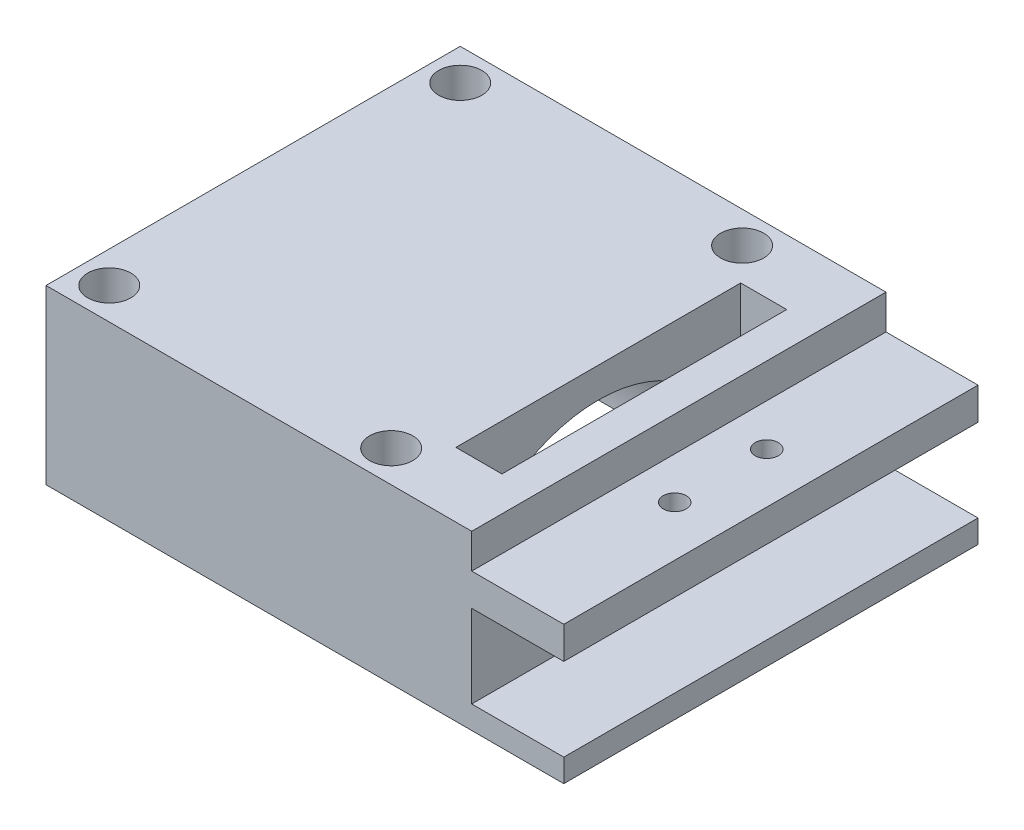
from build123d import *

# Parameters (mm, degrees)
SKETCH1_W           = 30
SKETCH1_H           = 36
BOSS_EXTRUDE1_DEPTH = 30
SKETCH3_R           = 12.375
CUT_EXTRUDE1_DEPTH  = 40
SKETCH5_R           = 1.875
CUT_EXTRUDE2_DEPTH  = 40
CUT_EXTRUDE3_START  = 15
SKETCH7_W           = 36
SKETCH7_H           = 15
CUT_EXTRUDE3_DEPTH  = 31
SKETCH8_W           = 5.625
SKETCH8_H           = 15
BOSS_EXTRUDE2_DEPTH = 7
SKETCH10_W          = 24.75
SKETCH10_H          = 15
BOSS_EXTRUDE3_DEPTH = 3
SKETCH11_W          = 36
SKETCH11_H          = 5.8
SKETCH11_H_2        = 2
BOSS_EXTRUDE4_DEPTH = 8
SKETCH12_W          = 8
SKETCH12_H          = 36
CUT_EXTRUDE4_DEPTH  = 3
SKETCH13_R          = 1
CUT_EXTRUDE5_DEPTH  = 3


with BuildPart() as part:
    # Sketch1 → Boss-Extrude1 (new body)
    with BuildSketch(Plane(origin=(0, 0, 0), x_dir=(1, 0, 0), z_dir=(0, 1, 0))):
        Rectangle(SKETCH1_W, SKETCH1_H)
    extrude(amount=BOSS_EXTRUDE1_DEPTH)

    # Sketch3 → Cut-Extrude1 (cut)
    with BuildSketch(Plane(origin=(15, 0, 0), x_dir=(0, 0, -1), z_dir=(1, 0, 0))):
        with Locations((0, 15)):
            Circle(SKETCH3_R)
    extrude(amount=-CUT_EXTRUDE1_DEPTH, mode=Mode.SUBTRACT)

    # Sketch5 → Cut-Extrude2 (cut)
    with BuildSketch(Plane(origin=(0, 30, 0), x_dir=(1, 0, 0), z_dir=(0, 1, 0))):
        with Locations((-12.25, 15.25)):
            Circle(SKETCH5_R)
        with Locations((-12.25, -15.25)):
            Circle(SKETCH5_R)
        with Locations((12.25, -15.25)):
            Circle(SKETCH5_R)
        with Locations((12.25, 15.25)):
            Circle(SKETCH5_R)
    extrude(amount=-CUT_EXTRUDE2_DEPTH, mode=Mode.SUBTRACT)

    # Sketch7 → Cut-Extrude3 (cut, through all)
    with BuildSketch(Plane(origin=(0, 0, 0), x_dir=(0, 0, -1), z_dir=(1, 0, 0)).offset(CUT_EXTRUDE3_START)):
        with Locations((0, 7.5)):
            Rectangle(SKETCH7_W, SKETCH7_H)
    extrude(amount=-CUT_EXTRUDE3_DEPTH, mode=Mode.SUBTRACT)

    # Sketch8 → Boss-Extrude2 (add)
    with BuildSketch(Plane(origin=(15, 0, 0), x_dir=(0, 0, -1), z_dir=(1, 0, 0))):
        with Locations((-15.1875, 22.5)):
            Rectangle(SKETCH8_W, SKETCH8_H)
        with Locations((15.1875, 22.5)):
            Rectangle(SKETCH8_W, SKETCH8_H)
    extrude(amount=BOSS_EXTRUDE2_DEPTH)

    # Sketch10 → Boss-Extrude3 (add)
    with BuildSketch(Plane(origin=(22, 0, 0), x_dir=(0, 0, -1), z_dir=(1, 0, 0))):
        with Locations((0, 22.5)):
            Rectangle(SKETCH10_W, SKETCH10_H)
    extrude(amount=-BOSS_EXTRUDE3_DEPTH)

    # Sketch11 → Boss-Extrude4 (add)
    with BuildSketch(Plane(origin=(22, 0, 0), x_dir=(0, 0, -1), z_dir=(1, 0, 0))):
        with Locations((0, 27.1)):
            Rectangle(SKETCH11_W, SKETCH11_H)
        with Locations((0, 16)):
            Rectangle(SKETCH11_W, SKETCH11_H_2)
    extrude(amount=BOSS_EXTRUDE4_DEPTH)

    # Sketch12 → Cut-Extrude4 (cut)
    with BuildSketch(Plane(origin=(0, 30, 0), x_dir=(1, 0, 0), z_dir=(0, 1, 0))):
        with Locations((26, 0)):
            Rectangle(SKETCH12_W, SKETCH12_H)
    extrude(amount=-CUT_EXTRUDE4_DEPTH, mode=Mode.SUBTRACT)

    # Sketch13 → Cut-Extrude5 (cut)
    with BuildSketch(Plane(origin=(0, 27, 0), x_dir=(1, 0, 0), z_dir=(0, 1, 0))):
        with Locations((25.64, 4)):
            Circle(SKETCH13_R)
        with Locations((25.64, -4)):
            Circle(SKETCH13_R)
    extrude(amount=-CUT_EXTRUDE5_DEPTH, mode=Mode.SUBTRACT)


solid = part.part
